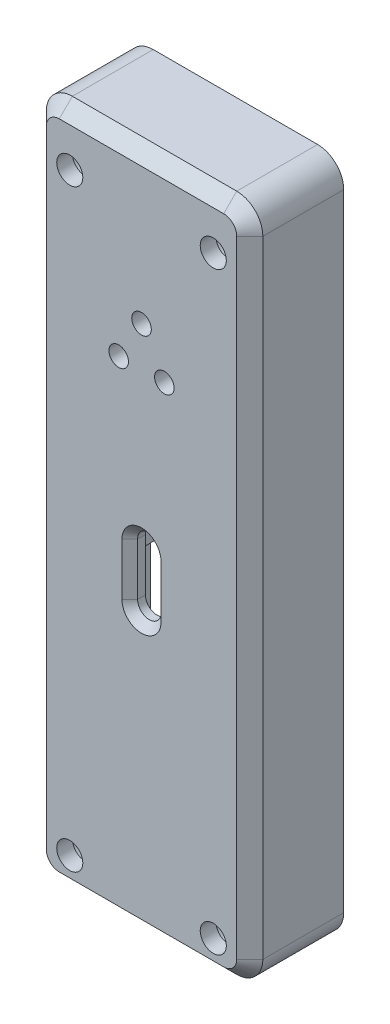
from build123d import *

# Parameters (mm, degrees)
EXTRUDE_1_DEPTH          = 34
SKETCH_2_W               = 16.6
SKETCH_2_H               = 7.2
EXTRUDE_2_DEPTH          = 18
CUT_EXTRUDE_2_DEPTH      = 2.2
CHAMFER_1_SIZE           = 0.6
EXTRUDE_4_DEPTH          = 2
SKETCH_8_R               = 1.6
EXTRUDE_5_DEPTH          = 6
CUT_EXTRUDE_4_DEPTH      = 6
SKETCH_9_R               = 1
CUT_EXTRUDE_5_DEPTH      = 7
CUT_EXTRUDE_5_DEPTH_BACK = 4
SKETCH_10_R              = 1.65
CUT_EXTRUDE_6_DEPTH      = 6
FILLET_1_R               = 2
SKETCH_13_R              = 0.75
CUT_EXTRUDE_9_DEPTH      = 8.2
FILLET_2_R               = 2
CHAMFER_2_SIZE           = 1


with BuildPart() as part:
    # Sketch 1 → Extrude 1 (new body)
    with BuildSketch(Plane(origin=(0, 0, 0), x_dir=(1, 0, 0), z_dir=(0, 1, 0))):
        Polygon((-6.5, 0), (6.5, 0), (6.5, 6), (8.3, 6), (8.3, -1.2), (-8.3, -1.2), (-8.3, 6), (-6.5, 6), align=None)
    extrude(amount=EXTRUDE_1_DEPTH)

    # Sketch 2 → Extrude 2 (add)
    with BuildSketch(Plane(origin=(0, 34, 0), x_dir=(1, 0, 0), z_dir=(0, 1, 0))):
        with Locations((0, 2.4)):
            Rectangle(SKETCH_2_W, SKETCH_2_H)
    extrude(amount=EXTRUDE_2_DEPTH)

    # Sketch 4 → Cut-Extrude 2 (cut, through all)
    with BuildSketch(Plane(origin=(0, 0, 0), x_dir=(-1, 0, 0), z_dir=(0, 0, -1))):
        with BuildLine():
            Line((0.9, 25.5), (0.9, 21.5))
            ThreePointArc((0.9, 21.5), (0, 20.6), (-0.9, 21.5))
            Line((-0.9, 21.5), (-0.9, 25.5))
            ThreePointArc((-0.9, 25.5), (0, 26.4), (0.9, 25.5))
        make_face()
    extrude(amount=-CUT_EXTRUDE_2_DEPTH, mode=Mode.SUBTRACT)

    # Chamfer 1
    chamfer_1_edges = [part.edges().sort_by_distance(p)[0] for p in [
        (0, 26.4, 1.2),
        (-0.9, 23.5, 1.2),
        (0, 20.6, 1.2),
        (0.9, 23.5, 1.2),
    ]]
    chamfer(chamfer_1_edges, length=CHAMFER_1_SIZE)

    # Sketch 5 → Extrude 4 (add, symmetric)
    with BuildSketch(Plane(origin=(0, 23.5, 0), x_dir=(-1, 0, 0), z_dir=(0, -1, 0))):
        Polygon((-6.5, 6), (-4.15, 6), (-4.15, 0.6), (-2.15, 0.6), (-2.15, 0), (-6.5, 0), align=None)
        Polygon((6.5, 0), (6.5, 6), (4.15, 6), (4.15, 0.6), (2.15, 0.6), (2.15, 0), align=None)
    extrude(amount=EXTRUDE_4_DEPTH, both=True)

    # Sketch 8 → Extrude 5 (add)
    with BuildSketch(Plane(origin=(0, 0, -6), x_dir=(-1, 0, 0), z_dir=(0, 0, -1))):
        with BuildLine():
            Line((-5.5, 5), (-8.3, 5))
            Line((-8.3, 5), (-8.3, 0))
            Line((-8.3, 0), (-5.5, 0))
            ThreePointArc((-5.5, 0), (-3, 2.5), (-5.5, 5))
        make_face()
        with Locations((-5.5, 2.5)):
            Circle(SKETCH_8_R, mode=Mode.SUBTRACT)
        with BuildLine():
            Line((8.3, 0), (5.5, 0))
            ThreePointArc((5.5, 0), (3, 2.5), (5.5, 5))
            Line((5.5, 5), (8.3, 5))
            Line((8.3, 5), (8.3, 0))
        make_face()
        with Locations((5.5, 2.5)):
            Circle(SKETCH_8_R, mode=Mode.SUBTRACT)
    extrude(amount=-EXTRUDE_5_DEPTH)

    # Sketch 8_2 → Cut-Extrude 4 (cut)
    with BuildSketch(Plane(origin=(0, 0, -6), x_dir=(-1, 0, 0), z_dir=(0, 0, -1))):
        with BuildLine():
            Line((-6.5, 1.2510004), (-6.5, 3.7489996))
            ThreePointArc((-6.5, 3.7489996), (-7.1, 2.5), (-6.5, 1.2510004))
        make_face()
        with BuildLine():
            ThreePointArc((-3.9, 2.5), (-4.807179677, 3.94222051), (-6.5, 3.7489996))
            Line((-6.5, 3.7489996), (-6.5, 1.2510004))
            ThreePointArc((-6.5, 1.2510004), (-4.807179677, 1.05777949), (-3.9, 2.5))
        make_face()
        with BuildLine():
            Line((6.5, 3.7489996), (6.5, 1.2510004))
            ThreePointArc((6.5, 1.2510004), (6.94222051, 1.807179677), (7.1, 2.5))
            ThreePointArc((7.1, 2.5), (6.94222051, 3.192820323), (6.5, 3.7489996))
        make_face()
        with BuildLine():
            ThreePointArc((6.5, 3.7489996), (3.9, 2.5), (6.5, 1.2510004))
            Line((6.5, 1.2510004), (6.5, 3.7489996))
        make_face()
    extrude(amount=-CUT_EXTRUDE_4_DEPTH, mode=Mode.SUBTRACT)

    # Sketch 9 → Cut-Extrude 5 (cut, two sides)
    with BuildSketch(Plane(origin=(0, 0, 0), x_dir=(-1, 0, 0), z_dir=(0, 0, -1))) as cut_extrude_5_sk:
        with Locations(Location((-5.5, 2.5, 0), (0, 0, 180))):  # turned: the seam where the file's is
            Circle(SKETCH_9_R)
        with Locations(Location((5.5, 2.5, 0), (0, 0, 180))):  # turned: the seam where the file's is
            Circle(SKETCH_9_R)
        with Locations(Location((5.5, 48, 0), (0, 0, 180))):  # turned: the seam where the file's is
            Circle(SKETCH_9_R)
        with Locations(Location((-5.5, 48, 0), (0, 0, 180))):  # turned: the seam where the file's is
            Circle(SKETCH_9_R)
    extrude(amount=CUT_EXTRUDE_5_DEPTH, mode=Mode.SUBTRACT)
    extrude(cut_extrude_5_sk.sketch, amount=-CUT_EXTRUDE_5_DEPTH_BACK, mode=Mode.SUBTRACT)

    # Sketch 10 → Cut-Extrude 6 (cut)
    with BuildSketch(Plane(origin=(0, 0, -6), x_dir=(-1, 0, 0), z_dir=(0, 0, -1))):
        with Locations((-5.5, 48)):
            Circle(SKETCH_10_R)
        with Locations((5.5, 48)):
            Circle(SKETCH_10_R)
    extrude(amount=-CUT_EXTRUDE_6_DEPTH, mode=Mode.SUBTRACT)

    # Fillet 1
    fillet_1_edges = [part.edges().sort_by_distance(p)[0] for p in [
        (-6.5, 34, -3),
        (6.5, 34, -3),
    ]]
    fillet(fillet_1_edges, radius=FILLET_1_R)

    # Sketch 13 → Cut-Extrude 9 (cut, through all)
    with BuildSketch(Plane(origin=(0, 0, -6), x_dir=(-1, 0, 0), z_dir=(0, 0, -1))):
        with Locations((0, 40.551155153)):
            Circle(SKETCH_13_R)
        with Locations((-1.75, 37.52006624)):
            Circle(SKETCH_13_R)
        with Locations((1.75, 37.52006624)):
            Circle(SKETCH_13_R)
    extrude(amount=-CUT_EXTRUDE_9_DEPTH, mode=Mode.SUBTRACT)

    # Fillet 2
    fillet_2_edges = [part.edges().sort_by_distance(p)[0] for p in [
        (-8.3, 52, -2.4),
        (8.3, 52, -2.4),
        (8.3, 0, -2.4),
        (-8.3, 0, -2.4),
    ]]
    fillet(fillet_2_edges, radius=FILLET_2_R)

    # Chamfer 2
    chamfer_2_edges = [part.edges().sort_by_distance(p)[0] for p in [
        (8.3, 26, 1.2),
        (0, 0, 1.2),
        (0, 52, 1.2),
        (-8.3, 26, 1.2),
        (-7.714213562, 51.414213562, 1.2),
        (7.714213562, 51.414213562, 1.2),
        (-7.714213562, 0.585786438, 1.2),
        (7.714213562, 0.585786438, 1.2),
    ]]
    chamfer(chamfer_2_edges, length=CHAMFER_2_SIZE)


solid = part.part
